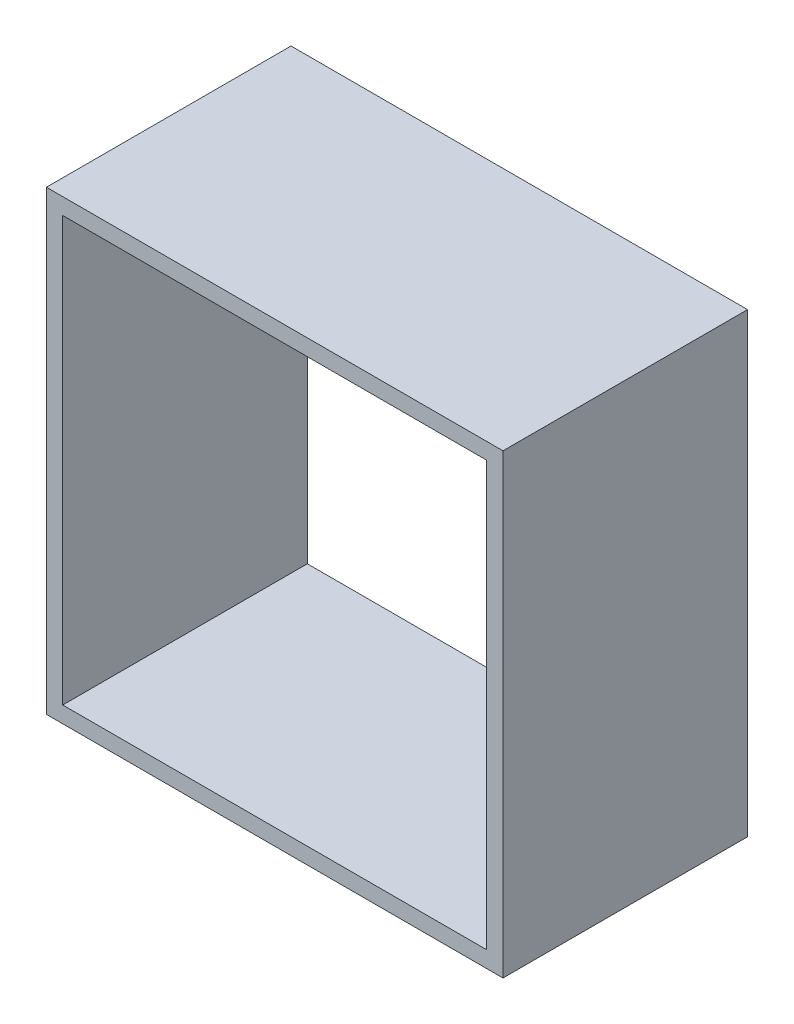
from build123d import *

# Parameters (mm, degrees)
SKETCH1_W           = 28
SKETCH1_H           = 28
SKETCH1_W_2         = 26
SKETCH1_H_2         = 26
BOSS_EXTRUDE1_DEPTH = 15


with BuildPart() as part:
    # Sketch1 → Boss-Extrude1 (new body)
    with BuildSketch(Plane.XY):
        Rectangle(SKETCH1_W, SKETCH1_H)
        Rectangle(SKETCH1_W_2, SKETCH1_H_2, mode=Mode.SUBTRACT)
    extrude(amount=BOSS_EXTRUDE1_DEPTH)


solid = part.part
